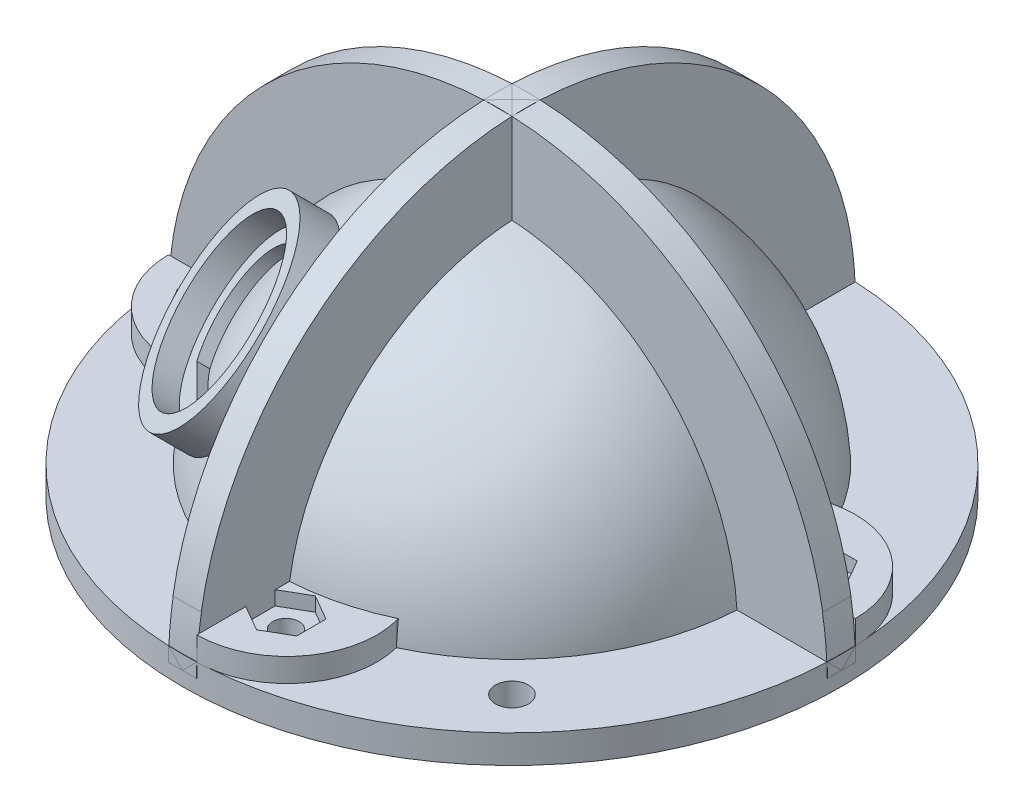
from build123d import *
from build123d.topology import SkipClean

# Parameters (mm, degrees)
BOSS_EXTRUDE1_DEPTH      = 1.5
BOSS_EXTRUDE1_DEPTH_BACK = 1.5
BOSS_EXTRUDE2_DEPTH      = 1.5
BOSS_EXTRUDE2_DEPTH_BACK = 1.5
SKETCH6_W                = 9.75
SKETCH6_H                = 3
SKETCH6_W_2              = 0.965
SKETCH6_H_2              = 1.5
BOSS_EXTRUDE4_START      = 2.5
BOSS_EXTRUDE4_DEPTH      = 2.5
CUT_EXTRUDE1_DEPTH       = 1.5
SKETCH11_R               = 1.4
CUT_EXTRUDE2_DEPTH       = 60.213596412
BOSS_EXTRUDE5_DEPTH      = 2
BOSS_EXTRUDE5_DEPTH_BACK = 5
SKETCH13_R               = 10.5
CUT_EXTRUDE3_DEPTH       = 10
CUT_EXTRUDE3_DEPTH_BACK  = 10
SKETCH15_R               = 9
CUT_EXTRUDE4_DEPTH       = 10
CUT_EXTRUDE5_DEPTH       = 4.1
SKETCH19_R               = 8.75
CUT_EXTRUDE6_DEPTH       = 2.5
SKETCH23_R               = 1.75
CUT_EXTRUDE9_DEPTH       = 10


with BuildPart() as part:
    # Sketch1 → Revolve1 (revolve)
    with BuildSketch(Plane.XY, mode=Mode.PRIVATE) as revolve1_sk:
        with BuildLine():
            Line((-20.885, 0), (-20.885, 11.793939121))
            ThreePointArc((-20.885, 11.793939121), (-12.091372858, 20.714220415), (0, 23.985))
            Line((0, 23.985), (0, 25.485))
            ThreePointArc((0, 25.485), (-18.020616319, 18.020616319), (-25.485, 0))
            Line((-25.485, 0), (-24.285, 0))
            Line((-24.285, 0), (-24.285, 0.5))
            Line((-24.285, 0.5), (-22.085, 0.5))
            Line((-22.085, 0.5), (-22.085, 0))
            Line((-22.085, 0), (-20.885, 0))
        make_face()
    revolve(revolve1_sk.sketch.rotate(Axis((0, 0, 0), (0, 1, 0)), 270), axis=Axis((0, 0, 0), (0, 1, 0)))



with BuildPart() as body_2:
    # Sketch2 → Boss-Extrude1 (new, two sides: drawn at the far end of the back side and taken through both)
    with BuildSketch(Plane.XY.offset(-BOSS_EXTRUDE1_DEPTH_BACK)):
        with BuildLine():
            Line((-24.9, 0), (-35, 0))
            ThreePointArc((-35, 0), (0, 35), (35, 0))
            Line((35, 0), (24.9, 0))
            ThreePointArc((24.9, 0), (0, 24.9), (-24.9, 0))
        make_face()
    extrude(amount=BOSS_EXTRUDE1_DEPTH + BOSS_EXTRUDE1_DEPTH_BACK)

    # Sketch3 → Boss-Extrude2 (add, two sides: drawn at the far end of the back side and taken through both)
    with BuildSketch(Plane(origin=(0, 0, 0), x_dir=(0, 0, -1), z_dir=(1, 0, 0)).offset(-BOSS_EXTRUDE2_DEPTH_BACK)):
        with BuildLine():
            Line((35, 0), (24.9, 0))
            ThreePointArc((24.9, 0), (0, 24.9), (-24.9, 0))
            Line((-24.9, 0), (-35, 0))
            ThreePointArc((-35, 0), (0, 35), (35, 0))
        make_face()
    extrude(amount=BOSS_EXTRUDE2_DEPTH + BOSS_EXTRUDE2_DEPTH_BACK)


with BuildPart() as part_1:
    add(part.part)

    add(body_2.part)  # Revolve3 merges body 2
    # Sketch6 → Revolve3 (revolve)
    with BuildSketch(Plane(origin=(0, 0, 0), x_dir=(0, 0, -1), z_dir=(1, 0, 0)), mode=Mode.PRIVATE) as revolve3_sk:
        with Locations((30.125, 0)):
            Rectangle(SKETCH6_W, SKETCH6_H)
        with Locations((24.7675, 0.75)):
            Rectangle(SKETCH6_W_2, SKETCH6_H_2)
    revolve(revolve3_sk.sketch.rotate(Axis((0, 0, 0), (0, -1, 0)), 180), axis=Axis((0, 0, 0), (0, -1, 0)))

    # Sketch9 → Cut-Revolve1 (revolve, cut)
    with BuildSketch(Plane.XY, mode=Mode.PRIVATE) as cut_revolve1_sk:
        with BuildLine():
            Line((34.507469645, 5.851028856), (35.470882951, 5.851028856))
            Line((35.470882951, 5.851028856), (35.470882951, 1.5))
            Line((35.470882951, 1.5), (34.96784237, 1.5))
            ThreePointArc((34.96784237, 1.5), (34.805712289, 3.682715312), (34.507469645, 5.851028856))
        make_face()
    revolve(cut_revolve1_sk.sketch.rotate(Axis((0, 0, 0), (0, 1, 0)), 180), axis=Axis((0, 0, 0), (0, 1, 0)), mode=Mode.SUBTRACT)

    # Sketch7 → Boss-Extrude4 (add)
    with SkipClean():  # the faces are left unmerged after this step: merging them gives an invalid solid
        with BuildSketch(Plane(origin=(0, 1.5, 0), x_dir=(1, 0, 0), z_dir=(0, 1, 0)).offset(BOSS_EXTRUDE4_START)):
            with BuildLine():
                Line((23.044996888, 10.777909974), (22.609782845, 10.667601403))
                ThreePointArc((22.609782845, 10.667601403), (24.220082694, 6.195772291), (24.954959427, 1.5))
                Line((24.954959427, 1.5), (25.396559314, 1.5))
                Line((25.396559314, 1.5), (34.96784237, 1.5))
                ThreePointArc((34.96784237, 1.5), (31.274568745, 9.053705347), (23.044996888, 10.777909974))
            make_face()
            with BuildLine():
                ThreePointArc((10.667601403, -22.609782845), (6.195772291, -24.220082694), (1.5, -24.954959427))
                Line((1.5, -24.954959427), (1.5, -25.396559314))
                Line((1.5, -25.396559314), (1.5, -34.96784237))
                ThreePointArc((1.5, -34.96784237), (9.053705347, -31.274568745), (10.777909974, -23.044996888))
                Line((10.777909974, -23.044996888), (10.667601403, -22.609782845))
            make_face()
            with BuildLine():
                Line((-25.396559314, -1.5), (-34.96784237, -1.5))
                ThreePointArc((-34.96784237, -1.5), (-31.274568745, -9.053705347), (-23.044996888, -10.777909974))
                Line((-23.044996888, -10.777909974), (-22.609782845, -10.667601403))
                ThreePointArc((-22.609782845, -10.667601403), (-24.220082694, -6.195772291), (-24.954959427, -1.5))
                Line((-24.954959427, -1.5), (-25.396559314, -1.5))
            make_face()
            with BuildLine():
                ThreePointArc((-2.626689255, 34.901296588), (-9.387133949, 30.818973666), (-10.777909974, 23.044996888))
                ThreePointArc((-10.777909974, 23.044996888), (-6.25053836, 24.661021779), (-1.5, 25.396559314))
                Line((-1.5, 25.396559314), (-1.5, 34.96784237))
                ThreePointArc((-1.5, 34.96784237), (-2.063612885, 34.939111349), (-2.626689255, 34.901296588))
            make_face()
            with BuildLine():
                Line((-10.777909974, 23.044996888), (-10.667601403, 22.609782845))
                ThreePointArc((-10.667601403, 22.609782845), (-6.195772291, 24.220082694), (-1.5, 24.954959427))
                Line((-1.5, 24.954959427), (-1.5, 25.396559314))
                ThreePointArc((-1.5, 25.396559314), (-6.25053836, 24.661021779), (-10.777909974, 23.044996888))
            make_face()
        extrude(amount=-BOSS_EXTRUDE4_DEPTH)

    # Sketch10 → Cut-Extrude1 (cut)
    with SkipClean():  # the faces are left unmerged after this step: merging them gives an invalid solid
        with BuildSketch(Plane(origin=(0, 4, 0), x_dir=(1, 0, 0), z_dir=(0, 1, 0))):
            Polygon((4.2, -31.327119097), (6.9, -29.76827337), (6.9, -26.650581916), (4.2, -25.091736189), (1.5, -26.650581916), (1.5, -29.76827337), align=None)
            Polygon((-25.091736189, -4.2), (-26.650581916, -1.5), (-29.76827337, -1.5), (-31.327119097, -4.2), (-29.76827337, -6.9), (-26.650581916, -6.9), align=None)
            Polygon((-4.2, 31.327119097), (-6.9, 29.76827337), (-6.9, 26.650581916), (-4.2, 25.091736189), (-1.5, 26.650581916), (-1.5, 29.76827337), align=None)
            Polygon((31.327119097, 4.2), (29.76827337, 6.9), (26.650581916, 6.9), (25.091736189, 4.2), (26.650581916, 1.5), (29.76827337, 1.5), align=None)
        extrude(amount=-CUT_EXTRUDE1_DEPTH, mode=Mode.SUBTRACT)

    # Sketch11 → Cut-Extrude2 (cut, through all)
    with SkipClean():  # the faces are left unmerged after this step: merging them gives an invalid solid
        with BuildSketch(Plane(origin=(0, 2.5, 0), x_dir=(1, 0, 0), z_dir=(0, 1, 0))):
            with Locations(Location((28.209427643, 4.2, 0), (0, 0, 270))):
                Circle(SKETCH11_R)
            with Locations(Location((4.2, -28.209427643, 0), (0, 0, 270))):
                Circle(SKETCH11_R)
            with Locations(Location((-28.209427643, -4.2, 0), (0, 0, 270))):
                Circle(SKETCH11_R)
            with Locations(Location((-4.2, 28.209427643, 0), (0, 0, 270))):
                Circle(SKETCH11_R)
        extrude(amount=-CUT_EXTRUDE2_DEPTH, mode=Mode.SUBTRACT)

    # Sketch13 → Boss-Extrude5 (add, two sides: drawn at the far end of the back side and taken through both)
    with SkipClean():  # the faces are left unmerged after this step: merging them gives an invalid solid
        with BuildSketch(Plane(origin=(-12.655947457, 12.655947457, 12.655947457), x_dir=(-0.8164965809277261, -0.408248290463863, -0.408248290463863), z_dir=(0.5773502691896257, -0.5773502691896258, -0.5773502691896258)).offset(-BOSS_EXTRUDE5_DEPTH_BACK)):
            with Locations(Location((0, 0, 0), (0, 0, 270))):
                Circle(SKETCH13_R)
        extrude(amount=BOSS_EXTRUDE5_DEPTH + BOSS_EXTRUDE5_DEPTH_BACK)

    # Sketch12 → Cut-Extrude3 (cut, two sides: drawn at the far end of the back side and taken through both)
    with SkipClean():  # the faces are left unmerged after this step: merging them gives an invalid solid
        with BuildSketch(Plane(origin=(-12.655947457, 12.655947457, 12.655947457), x_dir=(-0.8164965809277261, -0.408248290463863, -0.408248290463863), z_dir=(0.5773502691896257, -0.5773502691896258, -0.5773502691896258)).offset(-CUT_EXTRUDE3_DEPTH_BACK)):
            with BuildLine():
                Line((0.352106197, -6.089829327), (5.097893803, -3.349847575))
                ThreePointArc((5.097893803, -3.349847575), (5.282754963, 3.05), (-0.352106197, 6.089829327))
                Line((-0.352106197, 6.089829327), (-5.097893803, 3.349847575))
                ThreePointArc((-5.097893803, 3.349847575), (-5.282754963, -3.05), (0.352106197, -6.089829327))
            make_face()
        extrude(amount=CUT_EXTRUDE3_DEPTH + CUT_EXTRUDE3_DEPTH_BACK, mode=Mode.SUBTRACT)

    # Sketch15 → Cut-Extrude4 (cut)
    with SkipClean():  # the faces are left unmerged after this step: merging them gives an invalid solid
        with BuildSketch(Plane(origin=(-11.501246918, 11.501246918, 11.501246918), x_dir=(-0.40824829046386274, 0.40824829046386296, -0.8164965809277264), z_dir=(0.5773502691896258, -0.5773502691896262, -0.5773502691896255))):
            Circle(SKETCH15_R)
        extrude(amount=CUT_EXTRUDE4_DEPTH, mode=Mode.SUBTRACT)

    # Sketch18 → Cut-Extrude5 (cut)
    with SkipClean():  # the faces are left unmerged after this step: merging them gives an invalid solid
        with BuildSketch(Plane(origin=(-15.542698803, 15.542698803, 15.542698803), x_dir=(0.40824829046386274, -0.40824829046386296, 0.8164965809277264), z_dir=(-0.5773502691896258, 0.5773502691896262, 0.5773502691896255))):
            with BuildLine():
                Line((0.654858953, -7.06973548), (5.795141047, -4.101992229))
                ThreePointArc((5.795141047, -4.101992229), (6.148780367, 3.55), (-0.654858953, 7.06973548))
                ThreePointArc((-0.654858953, 7.06973548), (-3.55, 6.148780367), (-5.795141047, 4.101992229))
                ThreePointArc((-5.795141047, 4.101992229), (-6.148780367, -3.55), (0.654858953, -7.06973548))
            make_face()
        extrude(amount=-CUT_EXTRUDE5_DEPTH, mode=Mode.SUBTRACT)

    # Sketch19 → Cut-Extrude6 (cut)
    with SkipClean():  # the faces are left unmerged after this step: merging them gives an invalid solid
        with BuildSketch(Plane(origin=(-15.542698803, 15.542698803, 15.542698803), x_dir=(0.40824829046386274, -0.40824829046386296, 0.8164965809277264), z_dir=(-0.5773502691896258, 0.5773502691896262, 0.5773502691896255))):
            with Locations(Location((0, 0, 0), (0, 0, 270))):
                Circle(SKETCH19_R)
        extrude(amount=-CUT_EXTRUDE6_DEPTH, mode=Mode.SUBTRACT)

    # Sketch23 → Cut-Extrude9 (cut)
    with SkipClean():  # the faces are left unmerged after this step: merging them gives an invalid solid
        with BuildSketch(Plane(origin=(0, 1.5, 0), x_dir=(1, 0, 0), z_dir=(0, 1, 0))):
            with Locations(Location((21.213203436, -21.213203436, 0), (0, 0, 270))):
                Circle(SKETCH23_R)
            with Locations(Location((-21.213203436, 21.213203436, 0), (0, 0, 270))):
                Circle(SKETCH23_R)
        extrude(amount=-CUT_EXTRUDE9_DEPTH, mode=Mode.SUBTRACT)

    # Sketch25 → Revolve5 (revolve)
    with SkipClean():  # the faces are left unmerged after this step: merging them gives an invalid solid
        with BuildSketch(Plane(origin=(0, 0, 0), x_dir=(0, 0, -1), z_dir=(1, 0, 0)), mode=Mode.PRIVATE) as revolve5_sk:
            with BuildLine():
                ThreePointArc((0, 24.290146665), (-16.998031528, 17.351603648), (-24.285, 0.5))
                Line((-24.285, 0.5), (0, 0.5))
                Line((0, 0.5), (0, 24.290146665))
            make_face()
            with BuildLine():
                Line((0, 24.290146665), (0, 0.5))
                Line((0, 0.5), (24.285, 0.5))
                ThreePointArc((24.285, 0.5), (16.998031528, 17.351603648), (0, 24.290146665))
            make_face()
            with BuildLine():
                Line((0, 0.5), (-24.285, 0.5))
                ThreePointArc((-24.285, 0.5), (-17.351603648, -16.998031528), (0, -24.290146665))
                Line((0, -24.290146665), (0, 0))
                Line((0, 0), (0, 0.5))
            make_face()
            with BuildLine():
                Line((24.285, 0.5), (0, 0.5))
                Line((0, 0.5), (0, 0))
                Line((0, 0), (0, -24.290146665))
                ThreePointArc((0, -24.290146665), (17.175727423, -17.175727423), (24.290146665, 0))
                ThreePointArc((24.290146665, 0), (24.288859965, 0.250013244), (24.285, 0.5))
            make_face()
        revolve(revolve5_sk.sketch.rotate(Axis((0, 37.964507333, 0), (0, -1, 0)), 180), axis=Axis((0, 37.964507333, 0), (0, -1, 0)))

    # SurfaceCut2
    split(bisect_by=Plane(origin=(0, -1.5, 0), x_dir=(-1, 0, 0), z_dir=(0, -1, 0)), keep=Keep.BOTTOM)


solid = part_1.part
